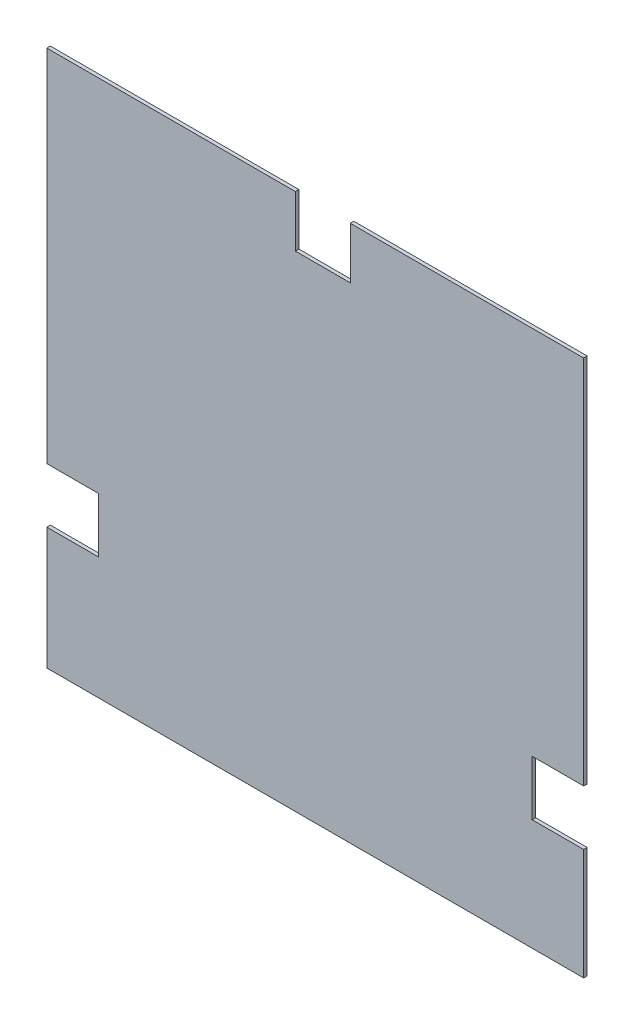
from build123d import *

# Parameters (mm, degrees)
BOSS_EXTRUDE1_DEPTH = 3


with BuildPart() as part:
    # Sketch1 → Boss-Extrude1 (new body)
    with BuildSketch(Plane.XY):
        Polygon((-10, 503), (-209.953752565, 503), (-209.953752565, 458.819491917), (-257.053752565, 458.819491917), (-257.053752565, 503), (-470, 503), (-470, 194.65), (-425.819491917, 194.65), (-425.819491917, 147.55), (-470, 147.55), (-470, 43), (-10, 43), (-10, 138.349963395), (-54.180508083, 138.349963395), (-54.180508083, 185.449963395), (-10, 185.449963395), align=None)
    extrude(amount=-BOSS_EXTRUDE1_DEPTH)


solid = part.part
